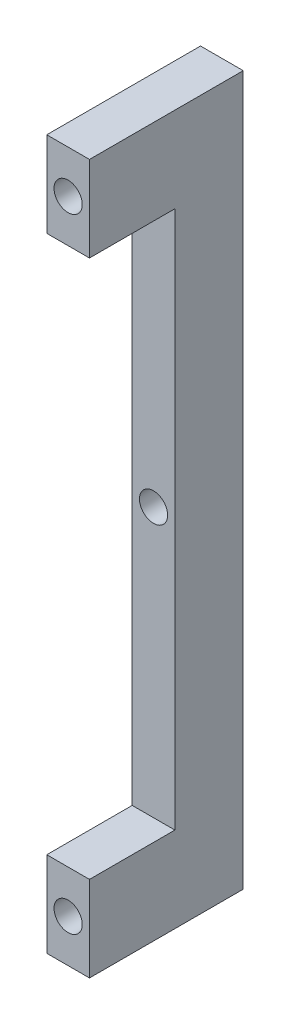
from build123d import *

# Parameters (mm, degrees)
ESQUISSE1_W             = 5
ESQUISSE1_H             = 83
BOSS_EXTRU_1_DEPTH      = 18
TROU_TARAUD_M4_D        = 3.3
ESQUISSE4_W             = 5
ESQUISSE4_H             = 63
ENL_V_MAT_EXTRU_1_DEPTH = 10


with BuildPart() as part:
    # Esquisse1 → Boss.-Extru.1 (new body)
    with BuildSketch(Plane.XY):
        with Locations((0, 36.5)):
            Rectangle(ESQUISSE1_W, ESQUISSE1_H)
    extrude(amount=-BOSS_EXTRU_1_DEPTH)

    # Trou taraudé M4 (through all)
    with Locations(Plane.XY):
        with Locations((0, 0), (0, 36.5), (0, 73)):
            Hole(TROU_TARAUD_M4_D / 2)

    # Esquisse4 → Enlèv. mat.-Extru.1 (cut)
    with BuildSketch(Plane.XY):
        with Locations((0, 36.5)):
            Rectangle(ESQUISSE4_W, ESQUISSE4_H)
    extrude(amount=-ENL_V_MAT_EXTRU_1_DEPTH, mode=Mode.SUBTRACT)


solid = part.part
